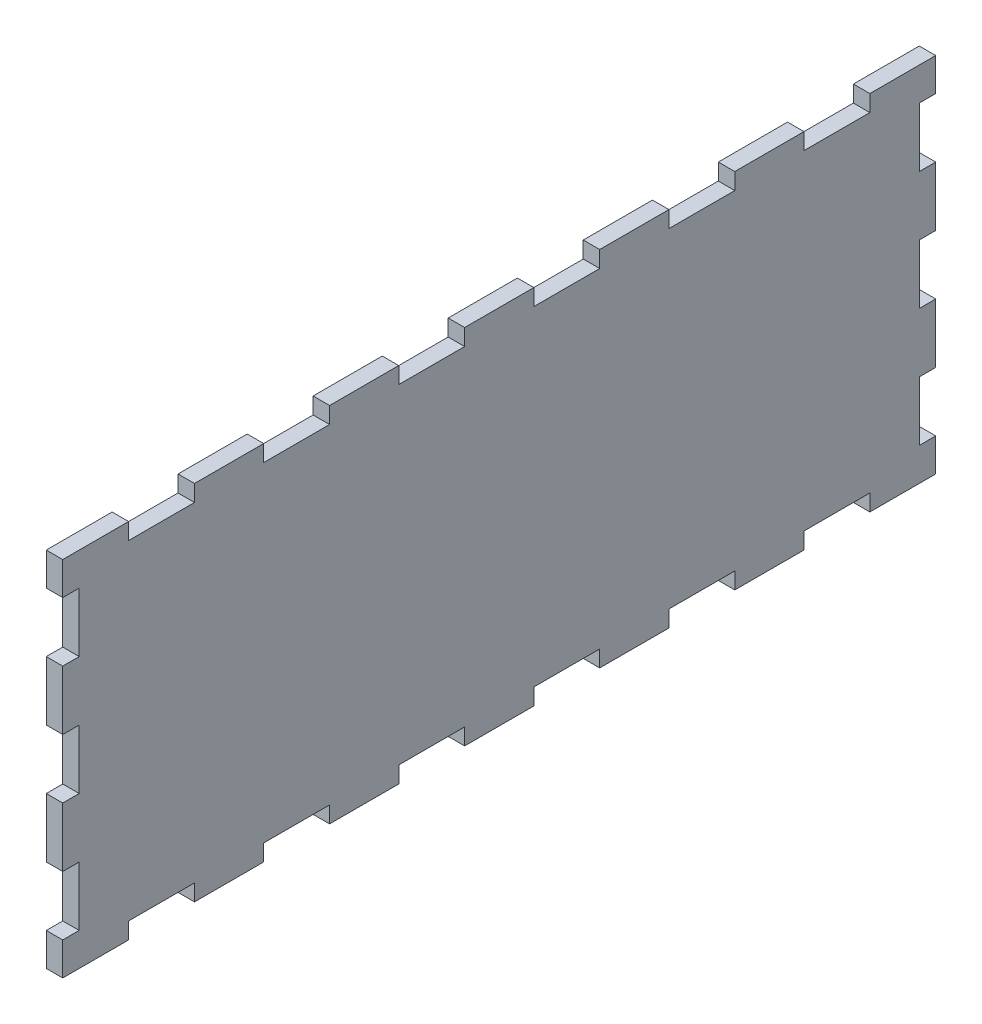
from build123d import *

# Parameters (mm, degrees)
SKETCH1_W           = 265
SKETCH1_H           = 110
BOSS_EXTRUDE1_DEPTH = 5
SKETCH2_W           = 5
SKETCH2_H           = 18
SKETCH2_W_2         = 20
SKETCH2_H_2         = 5
CUT_EXTRUDE1_DEPTH  = 5


with BuildPart() as part:
    # Sketch1 → Boss-Extrude1 (new body)
    with BuildSketch(Plane(origin=(0, 0, 0), x_dir=(0, 0, -1), z_dir=(1, 0, 0))):
        Rectangle(SKETCH1_W, SKETCH1_H)
    extrude(amount=BOSS_EXTRUDE1_DEPTH)

    # Sketch2 → Cut-Extrude1 (cut)
    with BuildSketch(Plane(origin=(5, 0, 0), x_dir=(0, 0, -1), z_dir=(1, 0, 0))):
        with Locations((-130, 36)):
            Rectangle(SKETCH2_W, SKETCH2_H)
        with Locations((-130, 0)):
            Rectangle(SKETCH2_W, SKETCH2_H)
        with Locations((-130, -36)):
            Rectangle(SKETCH2_W, SKETCH2_H)
        with Locations((130, -36)):
            Rectangle(SKETCH2_W, SKETCH2_H)
        with Locations((130, 0)):
            Rectangle(SKETCH2_W, SKETCH2_H)
        with Locations((130, 36)):
            Rectangle(SKETCH2_W, SKETCH2_H)
        with Locations((-61.5, 52.5)):
            Rectangle(SKETCH2_W_2, SKETCH2_H_2)
        with Locations((-102.5, 52.5)):
            Rectangle(SKETCH2_W_2, SKETCH2_H_2)
        with Locations((-20.5, 52.5)):
            Rectangle(SKETCH2_W_2, SKETCH2_H_2)
        with Locations((20.5, 52.5)):
            Rectangle(SKETCH2_W_2, SKETCH2_H_2)
        with Locations((61.5, 52.5)):
            Rectangle(SKETCH2_W_2, SKETCH2_H_2)
        with Locations((102.5, 52.5)):
            Rectangle(SKETCH2_W_2, SKETCH2_H_2)
        with Locations((102.5, -52.5)):
            Rectangle(SKETCH2_W_2, SKETCH2_H_2)
        with Locations((61.5, -52.5)):
            Rectangle(SKETCH2_W_2, SKETCH2_H_2)
        with Locations((20.5, -52.5)):
            Rectangle(SKETCH2_W_2, SKETCH2_H_2)
        with Locations((-20.5, -52.5)):
            Rectangle(SKETCH2_W_2, SKETCH2_H_2)
        with Locations((-61.5, -52.5)):
            Rectangle(SKETCH2_W_2, SKETCH2_H_2)
        with Locations((-102.5, -52.5)):
            Rectangle(SKETCH2_W_2, SKETCH2_H_2)
    extrude(amount=-CUT_EXTRUDE1_DEPTH, mode=Mode.SUBTRACT)


solid = part.part
